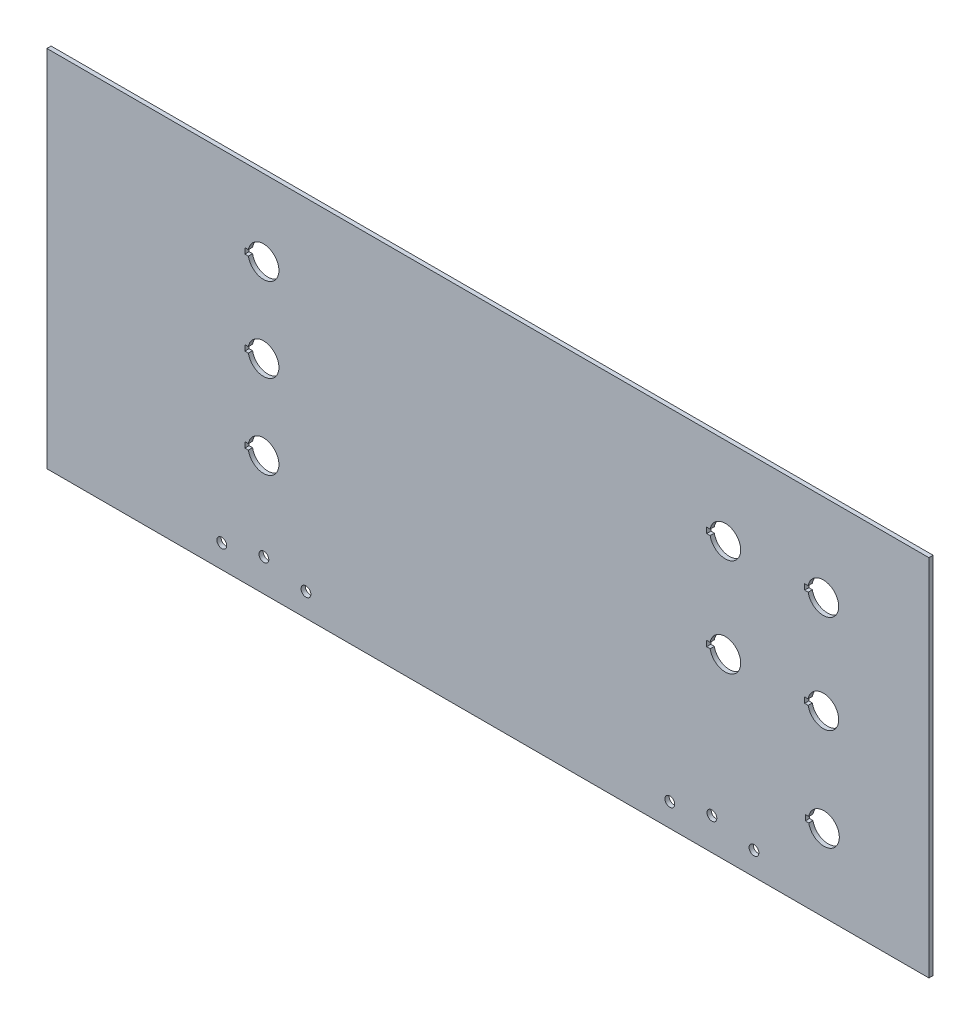
from build123d import *

# Parameters (mm, degrees)
CROQUIS1_W              = 630
CROQUIS1_H              = 260
SALIENTE_EXTRUIR1_DEPTH = 3
CORTAR_EXTRUIR1_DEPTH   = 4


with BuildPart() as part:
    # Croquis1 → Saliente-Extruir1 (new body)
    with BuildSketch(Plane.XY):
        Rectangle(CROQUIS1_W, CROQUIS1_H)
    extrude(amount=SALIENTE_EXTRUIR1_DEPTH)

    # Croquis2 → Cortar-Extruir1 (cut, through all)
    with BuildSketch(Plane(origin=(0, 0, 0), x_dir=(-1, 0, 0), z_dir=(0, 0, -1))):
        with BuildLine():
            Line((-228.740712327, -0.473268561), (-226.240712327, -0.473268561))
            Line((-226.240712327, -0.473268561), (-226.240712327, -4.473268561))
            Line((-226.240712327, -4.473268561), (-228.740712327, -4.473268561))
            ThreePointArc((-228.740712327, -4.473268561), (-250.557366154, -2.473268561), (-228.740712327, -0.473268561))
        make_face()
        with BuildLine():
            Line((-229.183346174, -73), (-226.683346174, -73))
            Line((-226.683346174, -73), (-226.683346174, -77))
            Line((-226.683346174, -77), (-229.183346174, -77))
            ThreePointArc((-229.183346174, -77), (-251, -75), (-229.183346174, -73))
        make_face()
        with BuildLine():
            Line((-158.740712327, -0.473268561), (-156.240712327, -0.473268561))
            Line((-156.240712327, -0.473268561), (-156.240712327, -4.473268561))
            Line((-156.240712327, -4.473268561), (-158.740712327, -4.473268561))
            ThreePointArc((-158.740712327, -4.473268561), (-180.557366154, -2.473268561), (-158.740712327, -0.473268561))
        make_face()
        with BuildLine():
            Line((-158.740712327, 69.526731439), (-156.240712327, 69.526731439))
            Line((-156.240712327, 69.526731439), (-156.240712327, 65.526731439))
            Line((-156.240712327, 65.526731439), (-158.740712327, 65.526731439))
            ThreePointArc((-158.740712327, 65.526731439), (-180.557366154, 67.526731439), (-158.740712327, 69.526731439))
        make_face()
        with BuildLine():
            Line((-228.740712327, 69.526731439), (-226.240712327, 69.526731439))
            Line((-226.240712327, 69.526731439), (-226.240712327, 65.526731439))
            Line((-226.240712327, 65.526731439), (-228.740712327, 65.526731439))
            ThreePointArc((-228.740712327, 65.526731439), (-250.557366154, 67.526731439), (-228.740712327, 69.526731439))
        make_face()
        with BuildLine():
            Line((171.091386036, -42.517832578), (173.591386036, -42.517832578))
            Line((173.591386036, -42.517832578), (173.591386036, -46.517832578))
            Line((173.591386036, -46.517832578), (171.091386036, -46.517832578))
            ThreePointArc((171.091386036, -46.517832578), (149.27473221, -44.517832578), (171.091386036, -42.517832578))
        make_face()
        with BuildLine():
            Line((171.091386036, 17.482167422), (173.591386036, 17.482167422))
            Line((173.591386036, 17.482167422), (173.591386036, 13.482167422))
            Line((173.591386036, 13.482167422), (171.091386036, 13.482167422))
            ThreePointArc((171.091386036, 13.482167422), (149.27473221, 15.482167422), (171.091386036, 17.482167422))
        make_face()
        with BuildLine():
            Line((171.091386036, 77.482167422), (173.591386036, 77.482167422))
            Line((173.591386036, 77.482167422), (173.591386036, 73.482167422))
            Line((173.591386036, 73.482167422), (171.091386036, 73.482167422))
            ThreePointArc((171.091386036, 73.482167422), (149.27473221, 75.482167422), (171.091386036, 77.482167422))
        make_face()
        with BuildLine():
            ThreePointArc((-163.5, -107), (-160, -110.5), (-156.5, -107))
            ThreePointArc((-156.5, -107), (-160, -103.5), (-163.5, -107))
        make_face()
        with BuildLine():
            ThreePointArc((-133.45, -113.4), (-129.95, -116.9), (-126.45, -113.4))
            ThreePointArc((-126.45, -113.4), (-129.95, -109.9), (-133.45, -113.4))
        make_face()
        with BuildLine():
            ThreePointArc((126.45, -113.4), (129.95, -116.9), (133.45, -113.4))
            ThreePointArc((133.45, -113.4), (129.95, -109.9), (126.45, -113.4))
        make_face()
        with BuildLine():
            ThreePointArc((156.5, -107), (160, -110.5), (163.5, -107))
            ThreePointArc((163.5, -107), (160, -103.5), (156.5, -107))
        make_face()
        with BuildLine():
            ThreePointArc((186.55, -113.4), (190.05, -116.9), (193.55, -113.4))
            ThreePointArc((193.55, -113.4), (190.05, -109.9), (186.55, -113.4))
        make_face()
        with BuildLine():
            ThreePointArc((-193.55, -113.4), (-190.05, -116.9), (-186.55, -113.4))
            ThreePointArc((-186.55, -113.4), (-190.05, -109.9), (-193.55, -113.4))
        make_face()
    extrude(amount=-CORTAR_EXTRUIR1_DEPTH, mode=Mode.SUBTRACT)


solid = part.part
